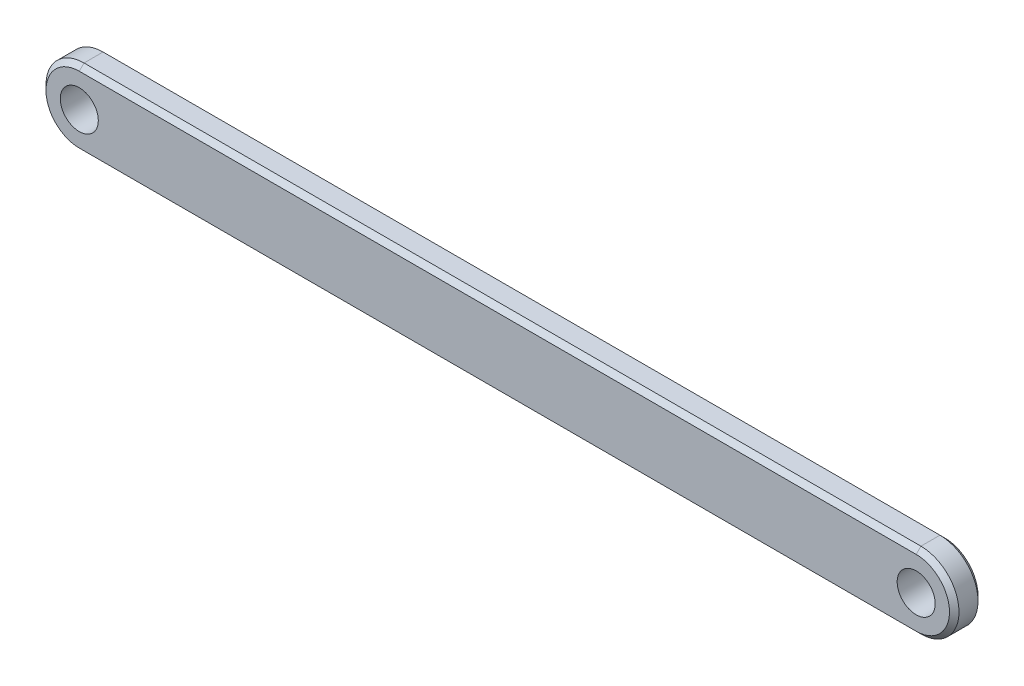
from build123d import *

# Parameters (mm, degrees)
SKETCH1_R           = 2
BOSS_EXTRUDE1_DEPTH = 1.5
CHAMFER1_SIZE       = 0.5


with BuildPart() as part:
    # Sketch1 → Boss-Extrude1 (new body, symmetric)
    with BuildSketch(Plane.XY):
        with BuildLine():
            Line((39.709091937, -4), (-48.290908063, -4))
            ThreePointArc((-48.290908063, -4), (-52.290908063, 0), (-48.290908063, 4))
            Line((-48.290908063, 4), (39.709091937, 4))
            ThreePointArc((39.709091937, 4), (43.709091937, 0), (39.709091937, -4))
        make_face()
        with Locations((-48.290908063, 0)):
            Circle(SKETCH1_R, mode=Mode.SUBTRACT)
        with Locations((39.709091937, 0)):
            Circle(SKETCH1_R, mode=Mode.SUBTRACT)
    extrude(amount=BOSS_EXTRUDE1_DEPTH, both=True)

    # Chamfer1
    chamfer1_edges = [part.edges().sort_by_distance(p)[0] for p in [
        (-52.290908063, 0, 1.5),
        (-4.290908063, -4, 1.5),
        (43.709091937, 0, 1.5),
        (-4.290908063, -4, -1.5),
        (-52.290908063, 0, -1.5),
        (-4.290908063, 4, -1.5),
        (43.709091937, 0, -1.5),
        (-4.290908063, 4, 1.5),
    ]]
    chamfer(chamfer1_edges, length=CHAMFER1_SIZE)


solid = part.part
